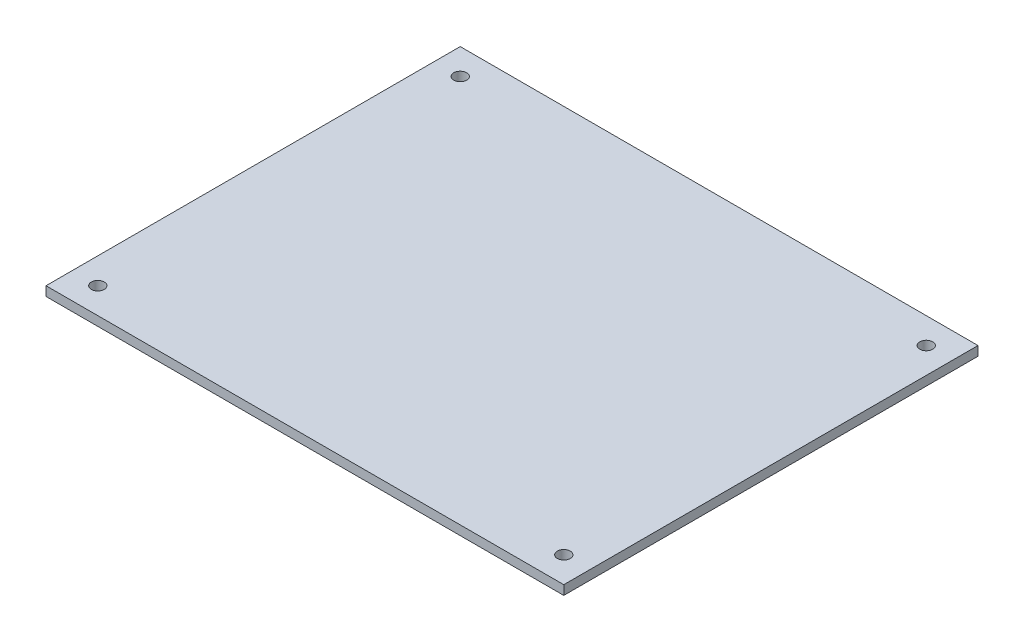
from build123d import *

# Parameters (mm, degrees)
SKETCH1_W           = 100
SKETCH1_H           = 80
BOSS_EXTRUDE1_DEPTH = 1.8
SKETCH2_R           = 1.25
CUT_EXTRUDE1_DEPTH  = 2.8


with BuildPart() as part:
    # Sketch1 → Boss-Extrude1 (new body)
    with BuildSketch(Plane(origin=(0, 0, 0), x_dir=(1, 0, 0), z_dir=(0, 1, 0))):
        Rectangle(SKETCH1_W, SKETCH1_H)
    extrude(amount=BOSS_EXTRUDE1_DEPTH)

    # Sketch2 → Cut-Extrude1 (cut, through all)
    with BuildSketch(Plane(origin=(0, 1.8, 0), x_dir=(1, 0, 0), z_dir=(0, 1, 0))):
        with Locations((-45, -35)):
            Circle(SKETCH2_R)
        with Locations((-45, 35)):
            Circle(SKETCH2_R)
        with Locations((45, 35)):
            Circle(SKETCH2_R)
        with Locations((45, -35)):
            Circle(SKETCH2_R)
    extrude(amount=-CUT_EXTRUDE1_DEPTH, mode=Mode.SUBTRACT)


solid = part.part
